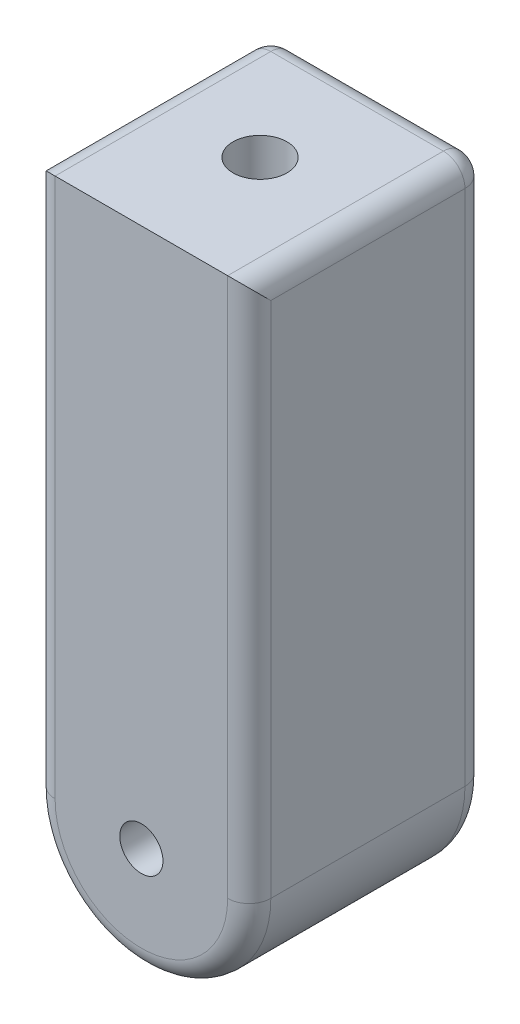
from build123d import *

# Parameters (mm, degrees)
SKETCH2_W           = 100
SKETCH2_H           = 200
BOSS_EXTRUDE1_DEPTH = 55
SKETCH3_R           = 10
CUT_EXTRUDE1_DEPTH  = 110
SKETCH4_R           = 12.5
CUT_EXTRUDE2_DEPTH  = 100
FILLET1_R           = 10


with BuildPart() as part:
    # Sketch2 → Boss-Extrude1 (new body, symmetric)
    with BuildSketch(Plane.XY):
        Rectangle(SKETCH2_W, SKETCH2_H)
        with BuildLine():
            ThreePointArc((50, -150), (0, -200), (-50, -150))
            Line((-50, -150), (-50, -100))
            Line((-50, -100), (50, -100))
            Line((50, -100), (50, -150))
        make_face()
    extrude(amount=BOSS_EXTRUDE1_DEPTH, both=True)

    # Sketch3 → Cut-Extrude1 (cut)
    with BuildSketch(Plane.XY.offset(55)):
        with Locations((0, -150)):
            Circle(SKETCH3_R)
    extrude(amount=-CUT_EXTRUDE1_DEPTH, mode=Mode.SUBTRACT)

    # Sketch4 → Cut-Extrude2 (cut)
    with BuildSketch(Plane(origin=(0, 100, 0), x_dir=(1, 0, 0), z_dir=(0, 1, 0))):
        Circle(SKETCH4_R)
    extrude(amount=-CUT_EXTRUDE2_DEPTH, mode=Mode.SUBTRACT)

    # Fillet1
    fillet1_edges = [part.edges().sort_by_distance(p)[0] for p in [
        (50, 100, 0),
        (-50, -25, 55),
        (-10, -150, -55),
        (0, -200, 55),
        (50, -25, 55),
        (0, -200, -55),
        (-50, -25, -55),
        (0, 100, -55),
        (50, -25, -55),
        (-50, 100, 0),
    ]]
    fillet(fillet1_edges, radius=FILLET1_R)


solid = part.part
